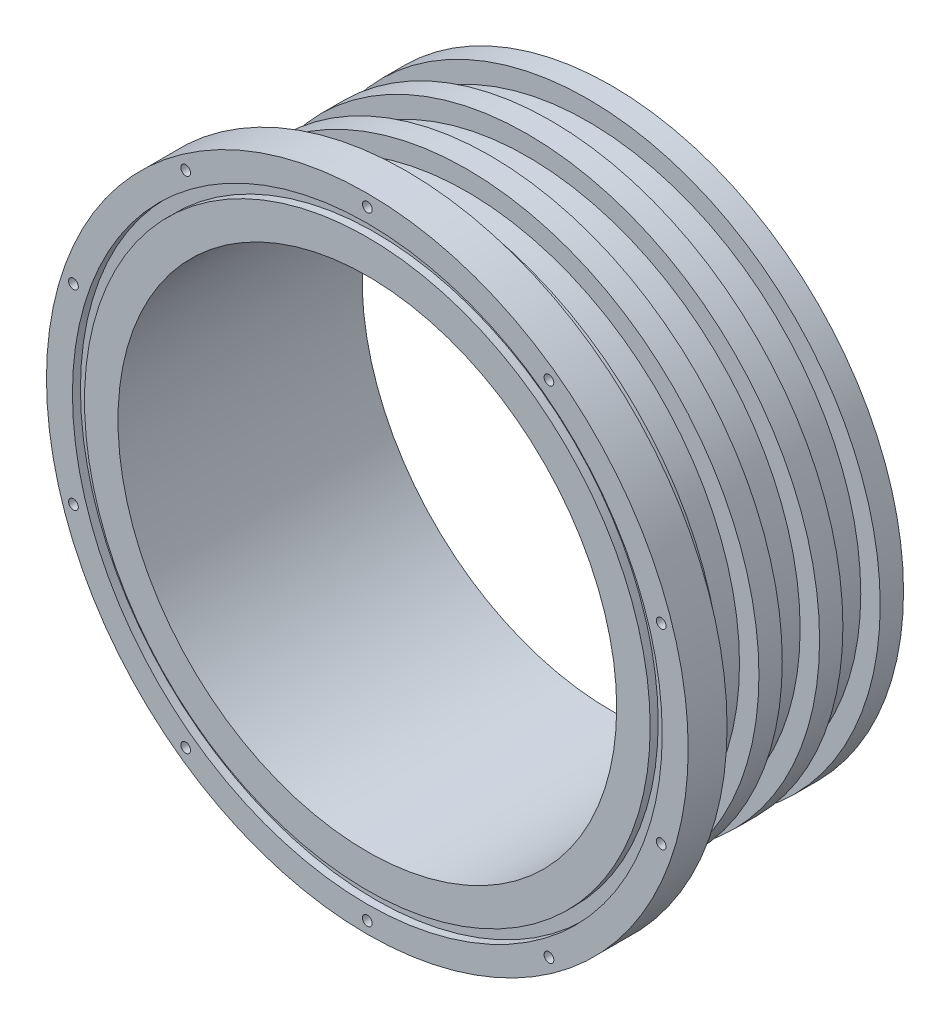
from build123d import *

# Parameters (mm, degrees)
M3X0_5_TAPPED_HOLE1_D = 2.5
SKETCH5_R             = 75.87
SKETCH5_R_2           = 72.77
CUT_EXTRUDE1_DEPTH    = 2.06


with BuildPart() as part:
    # Sketch1 → Revolve1 (revolve)
    with BuildSketch(Plane(origin=(0, 0, 0), x_dir=(1, 0, 0), z_dir=(0, 1, 0))):
        Polygon((-82.55, 0), (-82.55, 10), (-75.15, 10), (-75.15, 16), (-70.15, 16), (-70.15, 25.6), (-75.15, 25.6), (-75.15, 31.6), (-70.15, 31.6), (-70.15, 41.2), (-75.15, 41.2), (-75.15, 47.2), (-70.15, 47.2), (-70.15, 56.8), (-75.15, 56.8), (-75.15, 62.8), (-64.15, 62.8), (-64.15, 0), align=None)
    revolve(axis=Axis((0, 0, 0), (0, 0, -1)))

    # M3x0.5 Tapped Hole1 (through all)
    with Locations(Plane.XY):
        with Locations((0, 79.5), (46.728927557, 64.316851053), (75.608993045, 24.566851053), (75.608993045, -24.566851053), (46.728927557, -64.316851053), (0, -79.5), (-46.728927557, -64.316851053), (-75.608993045, -24.566851053), (-75.608993045, 24.566851053), (-46.728927557, 64.316851053)):
            Hole(M3X0_5_TAPPED_HOLE1_D / 2)

    # Sketch5 → Cut-Extrude1 (cut)
    with BuildSketch(Plane.XY):
        Circle(SKETCH5_R)
        Circle(SKETCH5_R_2, mode=Mode.SUBTRACT)
    extrude(amount=-CUT_EXTRUDE1_DEPTH, mode=Mode.SUBTRACT)


solid = part.part
